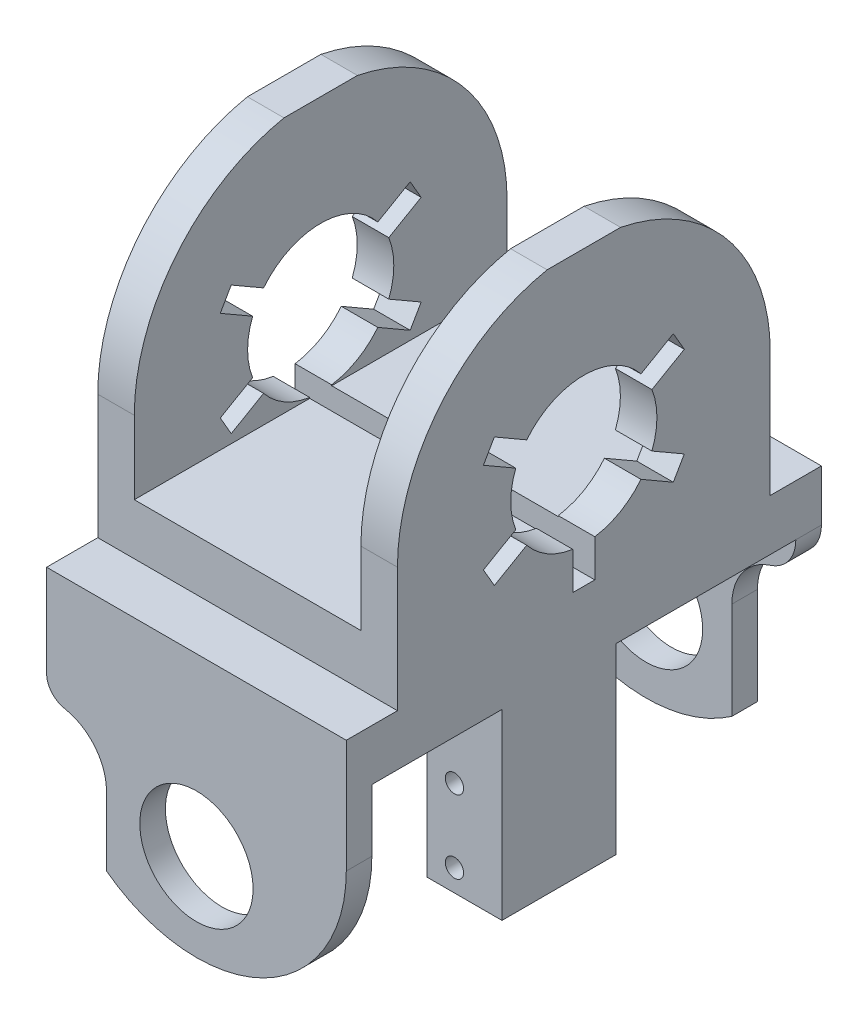
from build123d import *

# Parameters (mm, degrees)
BOSS_EXTRUDE1_DEPTH     = 20.5
SKETCH2_W               = 88
SKETCH2_H               = 51
SKETCH2_R               = 7.75
CUT_EXTRUDE1_DEPTH      = 66.463730416
CUT_EXTRUDE1_DEPTH_BACK = 66.463730416
SKETCH4_W               = 10.25
SKETCH4_H               = 15.6
BOSS_EXTRUDE2_DEPTH     = 25
CUT_EXTRUDE2_REACH      = 69.756
SKETCH5_R               = 1.25
SKETCH6_R               = 2.25
CUT_EXTRUDE3_DEPTH      = 29.3
CUT_EXTRUDE4_REACH      = 88.338
CUT_EXTRUDE5_DEPTH      = 3.5


with BuildPart() as part:
    # Sketch1 → Boss-Extrude1 (new, symmetric)
    with BuildSketch(Plane.YZ):
        with BuildLine():
            Line((-53, -32.5), (-17, -32.5))
            Line((-17, -32.5), (-17, -25.5))
            Line((-17, -25.5), (0, -25.5))
            ThreePointArc((0, -25.5), (25.5, 0), (0, 25.5))
            Line((0, 25.5), (-17, 25.5))
            Line((-17, 25.5), (-17, 32.5))
            Line((-17, 32.5), (-53, 32.5))
            Line((-53, 32.5), (-53, 29))
            Line((-53, 29), (-24, 29))
            Line((-24, 29), (-24, -29))
            Line((-24, -29), (-53, -29))
            Line((-53, -29), (-53, -32.5))
        make_face()
        with BuildLine():
            Line((-3.644391878, -9.312271895), (-6.200961894, -13.740381057))
            Line((-6.200961894, -13.740381057), (-8.799038106, -12.240381057))
            Line((-8.799038106, -12.240381057), (-6.242468089, -7.812271895))
            ThreePointArc((-6.242468089, -7.812271895), (-8.660254038, -5), (-9.886859967, -1.5))
            Line((-9.886859967, -1.5), (-15, -1.5))
            Line((-15, -1.5), (-15, 1.5))
            Line((-15, 1.5), (-9.886859967, 1.5))
            ThreePointArc((-9.886859967, 1.5), (-8.660254038, 5), (-6.242468089, 7.812271895))
            Line((-6.242468089, 7.812271895), (-8.799038106, 12.240381057))
            Line((-8.799038106, 12.240381057), (-6.200961894, 13.740381057))
            Line((-6.200961894, 13.740381057), (-3.644391878, 9.312271895))
            ThreePointArc((-3.644391878, 9.312271895), (0, 10), (3.644391878, 9.312271895))
            Line((3.644391878, 9.312271895), (6.200961894, 13.740381057))
            Line((6.200961894, 13.740381057), (8.799038106, 12.240381057))
            Line((8.799038106, 12.240381057), (6.242468089, 7.812271895))
            ThreePointArc((6.242468089, 7.812271895), (10, 0), (6.242468089, -7.812271895))
            Line((6.242468089, -7.812271895), (8.799038106, -12.240381057))
            Line((8.799038106, -12.240381057), (6.200961894, -13.740381057))
            Line((6.200961894, -13.740381057), (3.644391878, -9.312271895))
            ThreePointArc((3.644391878, -9.312271895), (0, -10), (-3.644391878, -9.312271895))
        make_face(mode=Mode.SUBTRACT)
    extrude(amount=BOSS_EXTRUDE1_DEPTH, both=True)

    # Sketch2 → Cut-Extrude1 (cut, two sides)
    with BuildSketch(Plane(origin=(0, 0, 0), x_dir=(0, 1, 0), z_dir=(0, 0, 1))) as cut_extrude1_sk:
        with Locations((-14, 0)):
            Rectangle(SKETCH2_W, SKETCH2_H)
        with BuildLine():
            Line((-10, 15.5), (25, 15.5))
            Line((25, 15.5), (25, 20.5))
            Line((25, 20.5), (-32.5, 20.5))
            ThreePointArc((-32.5, 20.5), (-53, 0), (-32.5, -20.5))
            Line((-32.5, -20.5), (25, -20.5))
            Line((25, -20.5), (25, -15.5))
            Line((25, -15.5), (-10, -15.5))
            Line((-10, -15.5), (-10, 15.5))
        make_face(mode=Mode.SUBTRACT)
        with Locations(Location((-41, 0, 0), (0, 0, 270))):
            Circle(SKETCH2_R)
    extrude(amount=CUT_EXTRUDE1_DEPTH, mode=Mode.SUBTRACT)
    extrude(cut_extrude1_sk.sketch, amount=-CUT_EXTRUDE1_DEPTH_BACK, mode=Mode.SUBTRACT)

    # Sketch4 → Boss-Extrude2 (add)
    with BuildSketch(Plane.XZ.offset(24)):
        with Locations((15.375, 3.4)):
            Rectangle(SKETCH4_W, SKETCH4_H)
    extrude(amount=BOSS_EXTRUDE2_DEPTH)

    # Sketch5 → Cut-Extrude2 (cut, up to next)
    with BuildSketch(Plane(origin=(0, 0, -4.4), x_dir=(1, 0, 0), z_dir=(0, 0, -1)), mode=Mode.PRIVATE) as cut_extrude2_sk1:
        with Locations(Location((14, 46, 0), (0, 0, 270))):
            Circle(SKETCH5_R)
    cut_extrude2_tool1 = extrude(cut_extrude2_sk1.sketch, amount=-CUT_EXTRUDE2_REACH, mode=Mode.PRIVATE) & part.part
    # Sketch5 → Cut-Extrude2 (cut, up to next)
    with BuildSketch(Plane(origin=(0, 0, -4.4), x_dir=(1, 0, 0), z_dir=(0, 0, -1)), mode=Mode.PRIVATE) as cut_extrude2_sk2:
        with Locations(Location((14, 36, 0), (0, 0, 180))):
            Circle(SKETCH5_R)
    cut_extrude2_tool2 = extrude(cut_extrude2_sk2.sketch, amount=-CUT_EXTRUDE2_REACH, mode=Mode.PRIVATE) & part.part
    add(cut_extrude2_tool1.solids().sort_by_distance((14, -46, -4.4))[0], mode=Mode.SUBTRACT)
    add(cut_extrude2_tool2.solids().sort_by_distance((14, -36, -4.4))[0], mode=Mode.SUBTRACT)

    # Sketch6 → Cut-Extrude3 (cut)
    with BuildSketch(Plane(origin=(0, 0, -32.5), x_dir=(1, 0, 0), z_dir=(0, 0, -1))):
        with Locations(Location((14, 46, 0), (0, 0, 270))):
            Circle(SKETCH6_R)
        with Locations(Location((14, 36, 0), (0, 0, 90))):
            Circle(SKETCH6_R)
    extrude(amount=-CUT_EXTRUDE3_DEPTH, mode=Mode.SUBTRACT)

    # Sketch7 → Cut-Extrude4 (cut, up to next)
    with BuildSketch(Plane.XY.offset(32.5), mode=Mode.PRIVATE) as cut_extrude4_sk1:
        with BuildLine():
            Line((-12.304878049, -39.397222885), (-12.304878049, -48.89634033))
            Line((-12.304878049, -48.89634033), (-20.5, -48.89634033))
            Line((-20.5, -48.89634033), (-20.5, -41.884242803))
            Line((-20.5, -41.884242803), (-20.5, -29.602755078))
            ThreePointArc((-20.5, -29.602755078), (-19.791785251, -31.497638771), (-18.041662968, -32.512145713))
            ThreePointArc((-18.041662968, -32.512145713), (-13.927029708, -34.916291372), (-12.304878049, -39.397222885))
        make_face()
    cut_extrude4_tool1 = extrude(cut_extrude4_sk1.sketch, amount=-CUT_EXTRUDE4_REACH, mode=Mode.PRIVATE) & part.part
    add(cut_extrude4_tool1.solids().sort_by_distance((-16.657353, -41.093277, 32.5))[0], mode=Mode.SUBTRACT)

    # Sketch9 → Cut-Extrude5 (cut)
    with BuildSketch(Plane(origin=(0, 0, -32.5), x_dir=(1, 0, 0), z_dir=(0, 0, -1))):
        with BuildLine():
            Line((20.5, 49.298437427), (20.5, 24))
            ThreePointArc((20.5, 24), (19.540037651, 26.945860787), (17.028761689, 28.760555398))
            ThreePointArc((17.028761689, 28.760555398), (13.209828458, 31.520187417), (11.75, 36))
            Line((11.75, 36), (11.75, 49.298437427))
            Line((11.75, 49.298437427), (20.5, 49.298437427))
        make_face()
    extrude(amount=-CUT_EXTRUDE5_DEPTH, mode=Mode.SUBTRACT)


solid = part.part
